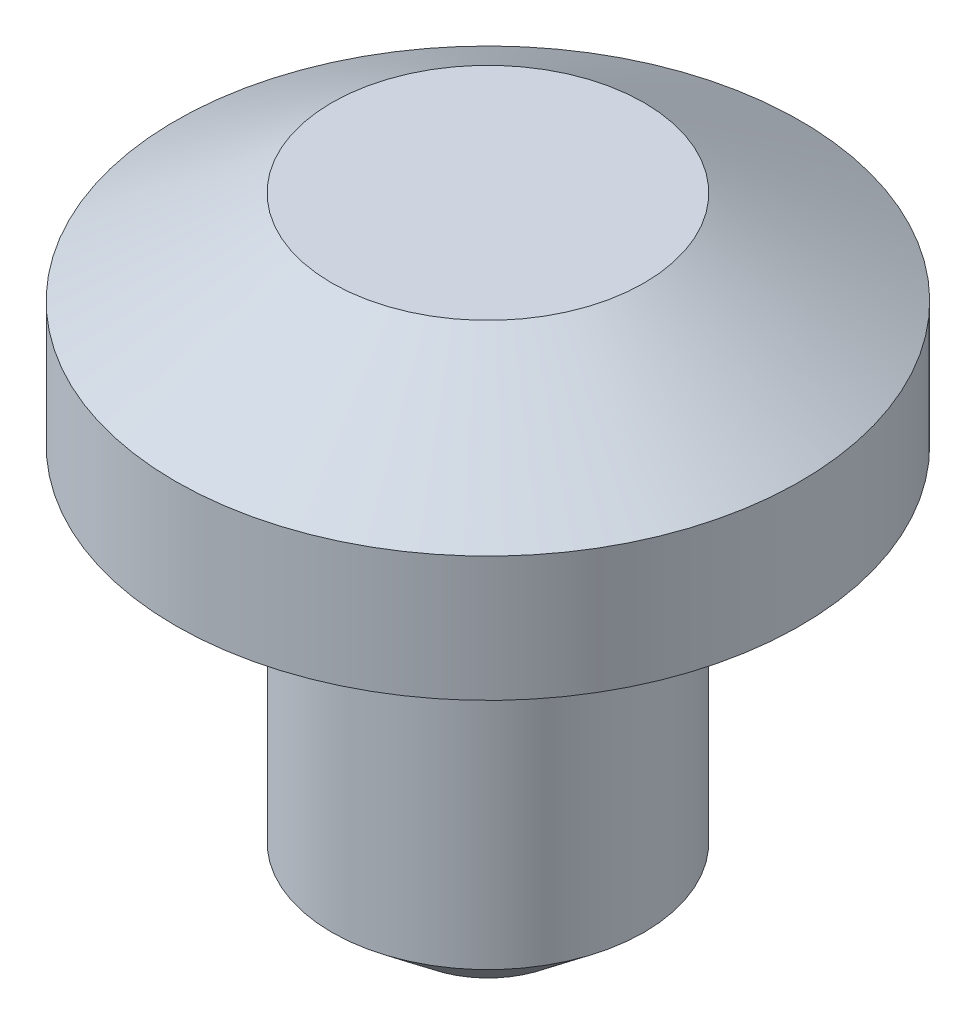
from build123d import *


with BuildPart() as part:
    # Sketch1 → Revolve1 (revolve)
    with BuildSketch(Plane.XY):
        Polygon((0, 63.5), (0, -63.5), (-31.75, -63.5), (-31.75, 0), (-63.5, 0), (-63.5, 63.5), align=None)
    revolve(axis=Axis((0, 63.5, 0), (0, -1, 0)))

    # Sketch3 → Cut-Revolve1 (revolve, cut)
    with BuildSketch(Plane(origin=(0, 0, 0), x_dir=(0, 0, -1), z_dir=(1, 0, 0))):
        Polygon((-63.5, 44.45), (-31.75, 63.5), (-63.5, 63.5), align=None)
        Polygon((-63.5, 19.05), (-63.5, 0), (-31.75, 0), align=None)
        Polygon((-15.875, -63.5), (-31.75, -50.8), (-31.75, -63.5), align=None)
    revolve(axis=Axis((0, 63.5, 0), (0, -1, 0)), mode=Mode.SUBTRACT)


solid = part.part
